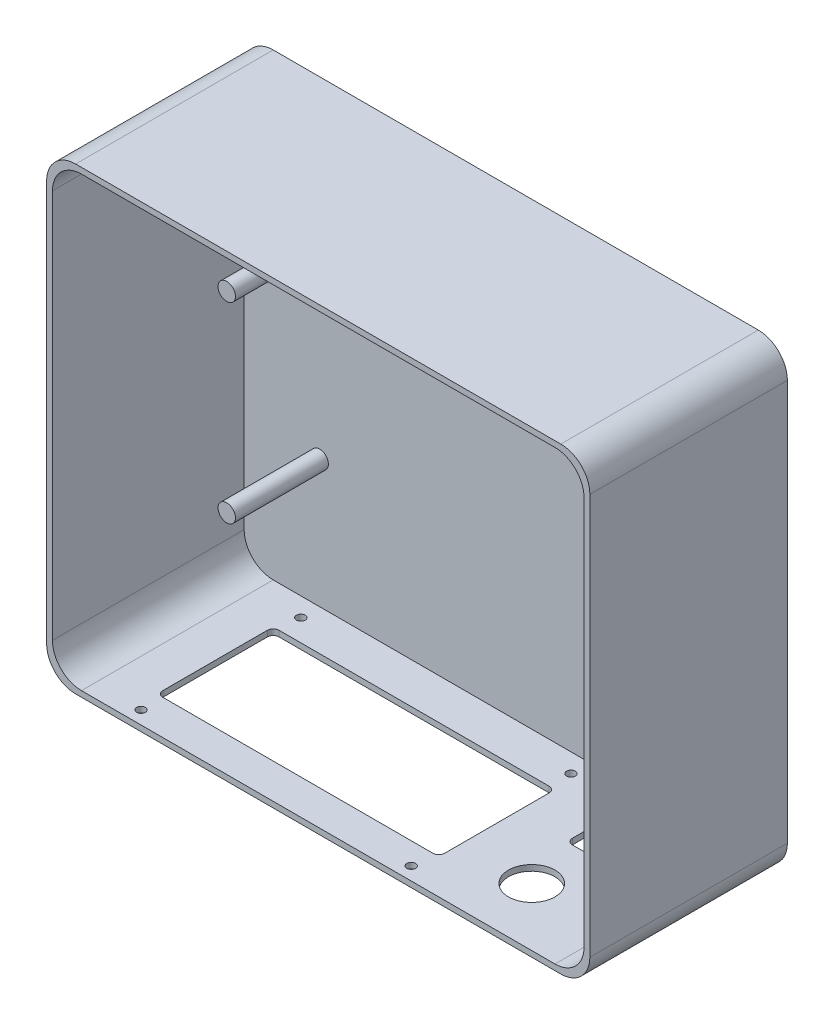
from build123d import *

# Parameters (mm, degrees)
SKETCH1_W           = 187
SKETCH1_H           = 158
SKETCH1_W_2         = 183
SKETCH1_H_2         = 154
BOSS_EXTRUDE1_DEPTH = 66
SKETCH2_W           = 187
SKETCH2_H           = 158
BOSS_EXTRUDE2_DEPTH = 2
FILLET1_R           = 10
FILLET2_R           = 10
SKETCH3_R           = 3
BOSS_EXTRUDE3_DEPTH = 32
SKETCH4_W           = 97
SKETCH4_H           = 40
CUT_EXTRUDE1_DEPTH  = 10
SKETCH5_R           = 1.5
CUT_EXTRUDE2_DEPTH  = 10
SKETCH6_R           = 8
SKETCH6_W           = 13
SKETCH6_H           = 19
CUT_EXTRUDE3_DEPTH  = 10
FILLET3_R           = 2


with BuildPart() as part:
    # Sketch1 → Boss-Extrude1 (new body)
    with BuildSketch(Plane.XY):
        Rectangle(SKETCH1_W, SKETCH1_H)
        Rectangle(SKETCH1_W_2, SKETCH1_H_2, mode=Mode.SUBTRACT)
    extrude(amount=BOSS_EXTRUDE1_DEPTH)

    # Sketch2 → Boss-Extrude2 (add)
    with BuildSketch(Plane(origin=(0, 0, 0), x_dir=(-1, 0, 0), z_dir=(0, 0, -1))):
        Rectangle(SKETCH2_W, SKETCH2_H)
    extrude(amount=BOSS_EXTRUDE2_DEPTH)

    # Fillet1
    fillet1_edges = [part.edges().sort_by_distance(p)[0] for p in [
        (91.5, -77, 33),
        (91.5, 77, 33),
        (-91.5, 77, 33),
        (-91.5, -77, 33),
    ]]
    fillet(fillet1_edges, radius=FILLET1_R)

    # Fillet2
    fillet2_edges = [part.edges().sort_by_distance(p)[0] for p in [
        (93.5, -79, 32),
        (-93.5, -79, 32),
        (-93.5, 79, 32),
        (93.5, 79, 32),
    ]]
    fillet(fillet2_edges, radius=FILLET2_R)

    # Sketch3 → Boss-Extrude3 (add)
    with BuildSketch(Plane.XY):
        with Locations((-65.5, 33)):
            Circle(SKETCH3_R)
        with Locations((65.5, 33)):
            Circle(SKETCH3_R)
        with Locations((65.5, -33)):
            Circle(SKETCH3_R)
        with Locations((-65.5, -33)):
            Circle(SKETCH3_R)
    extrude(amount=BOSS_EXTRUDE3_DEPTH)

    # Sketch4 → Cut-Extrude1 (cut)
    with BuildSketch(Plane.XZ.offset(79)):
        with Locations((-19, 34)):
            Rectangle(SKETCH4_W, SKETCH4_H)
    extrude(amount=-CUT_EXTRUDE1_DEPTH, mode=Mode.SUBTRACT)

    # Sketch5 → Cut-Extrude2 (cut)
    with BuildSketch(Plane.XZ.offset(79)):
        with Locations((-65.5, 61.5)):
            Circle(SKETCH5_R)
        with Locations((27.5, 61.5)):
            Circle(SKETCH5_R)
        with Locations((-65.5, 6.5)):
            Circle(SKETCH5_R)
        with Locations((27.5, 6.5)):
            Circle(SKETCH5_R)
    extrude(amount=-CUT_EXTRUDE2_DEPTH, mode=Mode.SUBTRACT)

    # Sketch6 → Cut-Extrude3 (cut)
    with BuildSketch(Plane.XZ.offset(79)):
        with Locations((53.5, 46)):
            Circle(SKETCH6_R)
        with Locations((53.5, 18)):
            Rectangle(SKETCH6_W, SKETCH6_H)
    extrude(amount=-CUT_EXTRUDE3_DEPTH, mode=Mode.SUBTRACT)

    # Fillet3
    fillet3_edges = [part.edges().sort_by_distance(p)[0] for p in [
        (29.5, -78, 54),
        (29.5, -78, 14),
        (-67.5, -78, 14),
        (-67.5, -78, 54),
        (60, -78, 27.5),
        (60, -78, 8.5),
        (47, -78, 8.5),
        (47, -78, 27.5),
    ]]
    fillet(fillet3_edges, radius=FILLET3_R)


solid = part.part
